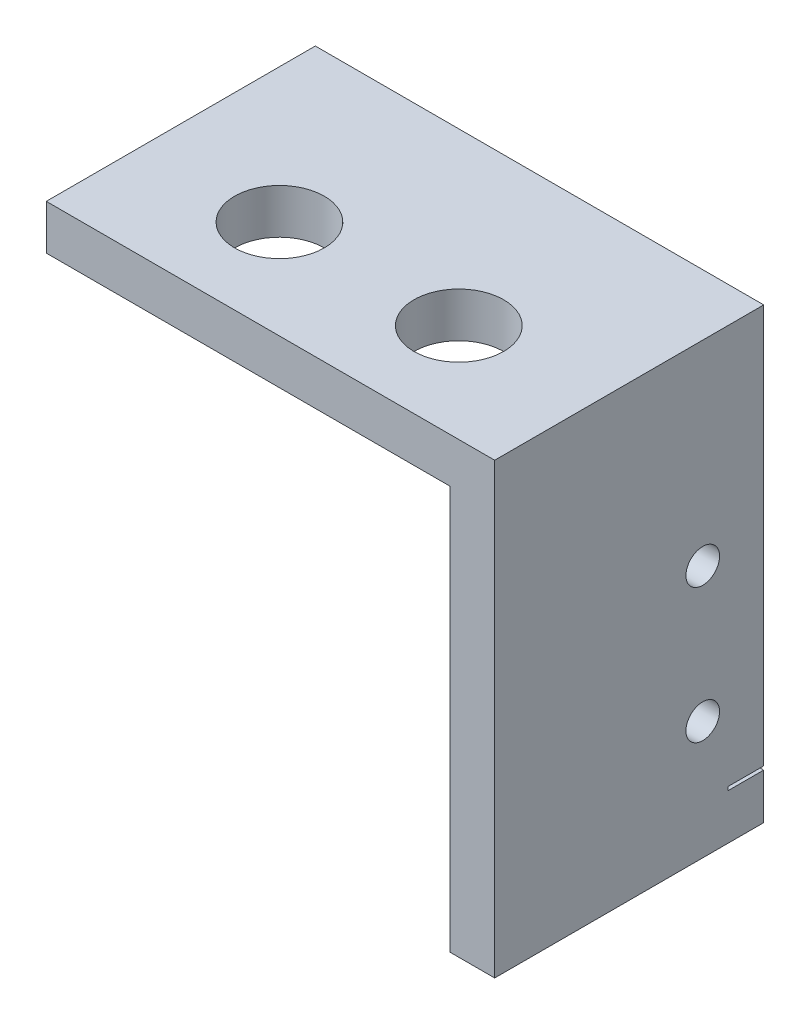
from build123d import *

# Parameters (mm, degrees)
SKETCH1_W           = 31.75
SKETCH1_H           = 3.175
SKETCH1_W_2         = 3.175
SKETCH1_H_2         = 28.575
BOSS_EXTRUDE1_DEPTH = 19.05
SWITCH_MOUNT_REACH  = 5.175
SKETCH2_R           = 1.190625
SKETCH2_W           = 2.54
SKETCH2_H           = 0.254
BRACKET_MOUNT_REACH = 5.175
SKETCH3_R           = 3.175


with BuildPart() as part:
    # Sketch1 → Boss-Extrude1 (new body)
    with BuildSketch(Plane.XY):
        with Locations((-15.875, 1.5875)):
            Rectangle(SKETCH1_W, SKETCH1_H)
        with Locations((-1.5875, -14.2875)):
            Rectangle(SKETCH1_W_2, SKETCH1_H_2)
    extrude(amount=BOSS_EXTRUDE1_DEPTH)

    # Sketch2 → Switch Mount (cut, up to next)
    with BuildSketch(Plane.ZY.offset(3.175), mode=Mode.PRIVATE) as switch_mount_sk1:
        with Locations((4.318, -10.668)):
            Circle(SKETCH2_R)
    switch_mount_tool1 = extrude(switch_mount_sk1.sketch, amount=-SWITCH_MOUNT_REACH, mode=Mode.PRIVATE) & part.part
    add(switch_mount_tool1.solids().sort_by_distance((-3.175, -10.668, 4.318))[0], mode=Mode.SUBTRACT)
    # Sketch2 → Switch Mount (cut, up to next)
    with BuildSketch(Plane.ZY.offset(3.175), mode=Mode.PRIVATE) as switch_mount_sk2:
        with Locations((4.318, -20.193)):
            Circle(SKETCH2_R)
    switch_mount_tool2 = extrude(switch_mount_sk2.sketch, amount=-SWITCH_MOUNT_REACH, mode=Mode.PRIVATE) & part.part
    add(switch_mount_tool2.solids().sort_by_distance((-3.175, -20.193, 4.318))[0], mode=Mode.SUBTRACT)
    # Sketch2 → Switch Mount (cut, up to next)
    with BuildSketch(Plane.ZY.offset(3.175), mode=Mode.PRIVATE) as switch_mount_sk3:
        with Locations((1.27, -25.2222)):
            Rectangle(SKETCH2_W, SKETCH2_H)
    switch_mount_tool3 = extrude(switch_mount_sk3.sketch, amount=-SWITCH_MOUNT_REACH, mode=Mode.PRIVATE) & part.part
    add(switch_mount_tool3.solids().sort_by_distance((-3.175, -25.2222, 1.27))[0], mode=Mode.SUBTRACT)

    # Sketch3 → Bracket Mount (cut, up to next)
    with BuildSketch(Plane.XZ, mode=Mode.PRIVATE) as bracket_mount_sk1:
        with Locations((-9.525, 12.065)):
            Circle(SKETCH3_R)
    bracket_mount_tool1 = extrude(bracket_mount_sk1.sketch, amount=-BRACKET_MOUNT_REACH, mode=Mode.PRIVATE) & part.part
    add(bracket_mount_tool1.solids().sort_by_distance((-9.525, 0, 12.065))[0], mode=Mode.SUBTRACT)
    # Sketch3 → Bracket Mount (cut, up to next)
    with BuildSketch(Plane.XZ, mode=Mode.PRIVATE) as bracket_mount_sk2:
        with Locations((-22.225, 12.065)):
            Circle(SKETCH3_R)
    bracket_mount_tool2 = extrude(bracket_mount_sk2.sketch, amount=-BRACKET_MOUNT_REACH, mode=Mode.PRIVATE) & part.part
    add(bracket_mount_tool2.solids().sort_by_distance((-22.225, 0, 12.065))[0], mode=Mode.SUBTRACT)


solid = part.part
